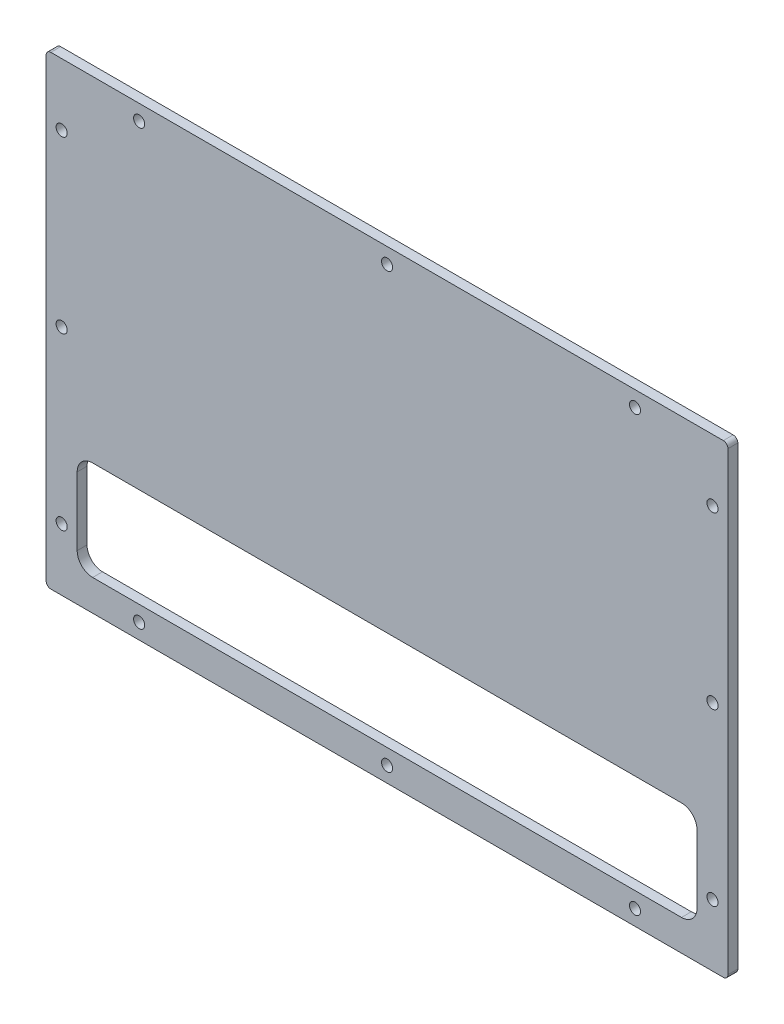
from build123d import *

# Parameters (mm, degrees)
SKETCH1_W            = 220
SKETCH1_H            = 150
BOSS_EXTRUDE1_DEPTH  = 3.175
M3_CLEARANCE_HOLE1_D = 3.6
SKETCH4_W            = 10
SKETCH4_H            = 10
BOSS_EXTRUDE2_DEPTH  = 3.175
FILLET2_R            = 1.5
SKETCH5_W            = 200
SKETCH5_H            = 32
CUT_EXTRUDE1_DEPTH   = 4.175
FILLET3_R            = 5


with BuildPart() as part:
    # Sketch1 → Boss-Extrude1 (new body)
    with BuildSketch(Plane.XY):
        Rectangle(SKETCH1_W, SKETCH1_H)
    extrude(amount=BOSS_EXTRUDE1_DEPTH)

    # M3 Clearance Hole1 (through all)
    with Locations(Plane.XY.offset(3.175)):
        with Locations((0, 0), (-80, 70), (80, 70), (0, 70), (-105, 55), (-105, 0), (-105, -55), (-80, -70), (0, -70), (80, -70), (105, -55), (105, 0), (105, 55)):
            Hole(M3_CLEARANCE_HOLE1_D / 2)

    # Sketch4 → Boss-Extrude2 (add, through all)
    with BuildSketch(Plane.XY.offset(3.175)):
        Rectangle(SKETCH4_W, SKETCH4_H)
    extrude(amount=-BOSS_EXTRUDE2_DEPTH)

    # Fillet2
    fillet2_edges = [part.edges().sort_by_distance(p)[0] for p in [
        (-110, -75, 1.5875),
        (-110, 75, 1.5875),
        (110, 75, 1.5875),
        (110, -75, 1.5875),
    ]]
    fillet(fillet2_edges, radius=FILLET2_R)

    # Sketch5 → Cut-Extrude1 (cut, through all)
    with BuildSketch(Plane.XY.offset(3.175)):
        with Locations((0, -49)):
            Rectangle(SKETCH5_W, SKETCH5_H)
    extrude(amount=-CUT_EXTRUDE1_DEPTH, mode=Mode.SUBTRACT)

    # Fillet3
    fillet3_edges = [part.edges().sort_by_distance(p)[0] for p in [
        (100, -33, 1.5875),
        (100, -65, 1.5875),
        (-100, -65, 1.5875),
        (-100, -33, 1.5875),
    ]]
    fillet(fillet3_edges, radius=FILLET3_R)


solid = part.part
